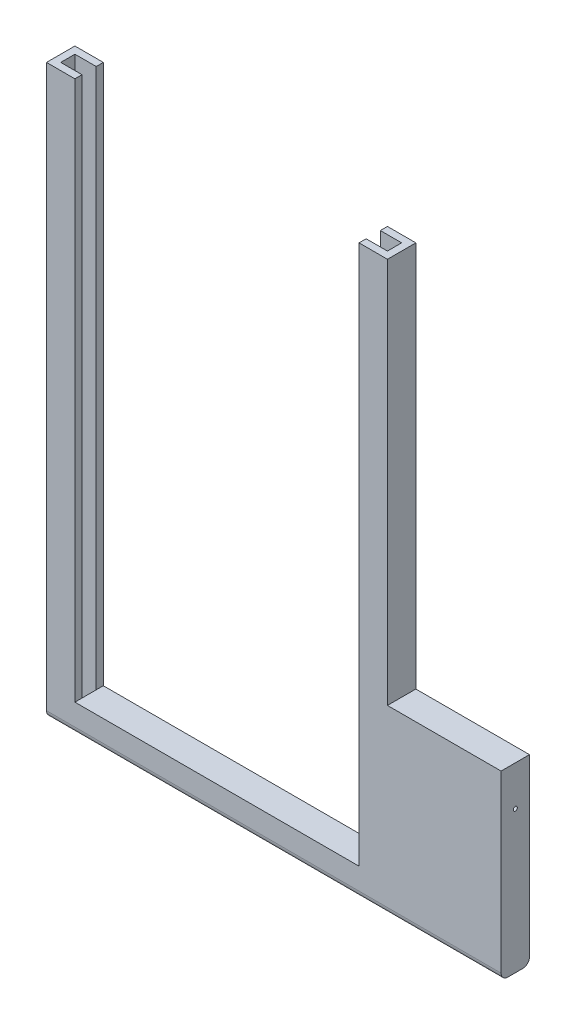
from build123d import *

# Parameters (mm, degrees)
BOSS_EXTRUDE1_DEPTH = 5
SKETCH4_W           = 3.75
SKETCH4_H           = 2.5
CUT_EXTRUDE2_DEPTH  = 101
SKETCH5_R           = 0.36
CUT_EXTRUDE3_DEPTH  = 81
FILLET1_R           = 1.2
FILLET2_R           = 1.2


with BuildPart() as part:
    # Sketch1 → Boss-Extrude1 (new body)
    with BuildSketch(Plane.XY):
        Polygon((0, 0), (0, 100), (5, 100), (5, 5), (55, 5), (55, 100), (60, 100), (60, 50), (60, 32), (80, 32), (80, 0), align=None)
    extrude(amount=BOSS_EXTRUDE1_DEPTH)

    # Sketch4 → Cut-Extrude2 (cut, through all)
    with BuildSketch(Plane(origin=(0, 100, 0), x_dir=(1, 0, 0), z_dir=(0, 1, 0))):
        with Locations((56.875, -2.5)):
            Rectangle(SKETCH4_W, SKETCH4_H)
        with Locations((3.125, -2.5)):
            Rectangle(SKETCH4_W, SKETCH4_H)
    extrude(amount=-CUT_EXTRUDE2_DEPTH, mode=Mode.SUBTRACT)

    # Sketch5 → Cut-Extrude3 (cut, through all)
    with BuildSketch(Plane(origin=(80, 0, 0), x_dir=(0, 0, -1), z_dir=(1, 0, 0))):
        with Locations((-2.5, 25)):
            Circle(SKETCH5_R)
    extrude(amount=-CUT_EXTRUDE3_DEPTH, mode=Mode.SUBTRACT)

    # Fillet1
    fillet1_edges = [part.edges().sort_by_distance(p)[0] for p in [
        (40, 0, 0),
    ]]
    fillet(fillet1_edges, radius=FILLET1_R)

    # Fillet2
    fillet2_edges = [part.edges().sort_by_distance(p)[0] for p in [
        (40, 0, 5),
    ]]
    fillet(fillet2_edges, radius=FILLET2_R)


solid = part.part
